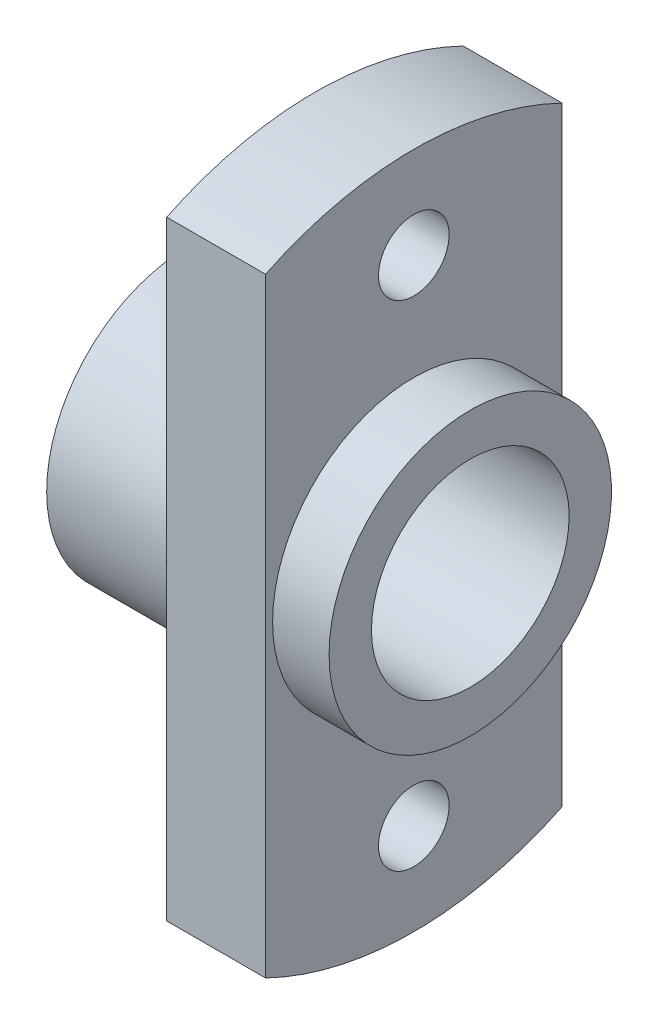
from build123d import *

# Parameters (mm, degrees)
M8X1_0_TAPPED_HOLE1_D = 7
SKETCH6_R             = 1.25
SKETCH6_W             = 17.472275608
SKETCH6_H             = 29.884909838
SKETCH6_W_2           = 8.845933312
CUT_EXTRUDE1_DEPTH    = 3.5


with BuildPart() as part:
    # Sketch1 → Revolve1 (revolve)
    with BuildSketch(Plane.XY):
        Polygon((0, 0), (0, 5), (4.5, 5), (4.5, 12), (8, 12), (8, 5), (10, 5), (10, 0), align=None)
    revolve(axis=Axis((-27.226239534, 0, 0), (1, 0, 0)))

    # M8x1.0 Tapped Hole1 (through all)
    with Locations(Plane(origin=(10, 0, 0), x_dir=(0, 0, -1), z_dir=(1, 0, 0))):
        with Locations((0, 0)):
            Hole(M8X1_0_TAPPED_HOLE1_D / 2)

    # Sketch6 → Cut-Extrude1 (cut)
    with BuildSketch(Plane(origin=(8, 0, 0), x_dir=(0, 0, -1), z_dir=(1, 0, 0))):
        with Locations((0, 8.75)):
            Circle(SKETCH6_R)
        with Locations((0, -8.75)):
            Circle(SKETCH6_R)
        with Locations((13.986137804, 0)):
            Rectangle(SKETCH6_W, SKETCH6_H)
        with Locations((-9.672966656, 0)):
            Rectangle(SKETCH6_W_2, SKETCH6_H)
    extrude(amount=-CUT_EXTRUDE1_DEPTH, mode=Mode.SUBTRACT)


solid = part.part
